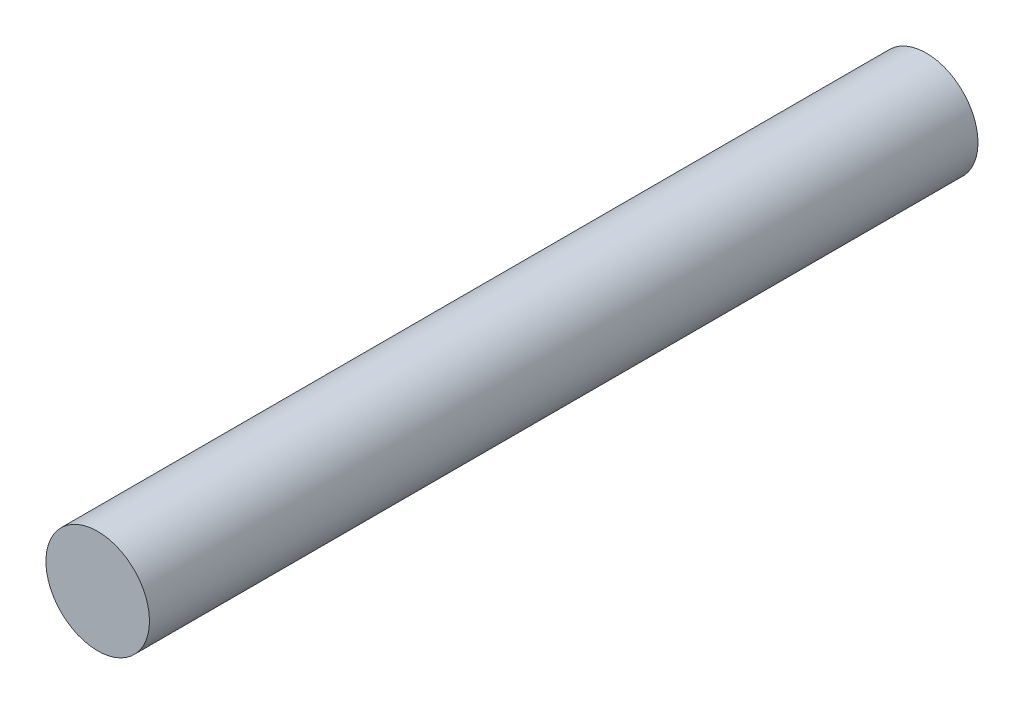
from build123d import *

# Parameters (mm, degrees)
SKETCH1_R           = 1.5875
BOSS_EXTRUDE1_DEPTH = 25.4


with BuildPart() as part:
    # Sketch1 → Boss-Extrude1 (new body)
    with BuildSketch(Plane.XY):
        Circle(SKETCH1_R)
    extrude(amount=BOSS_EXTRUDE1_DEPTH)


solid = part.part
